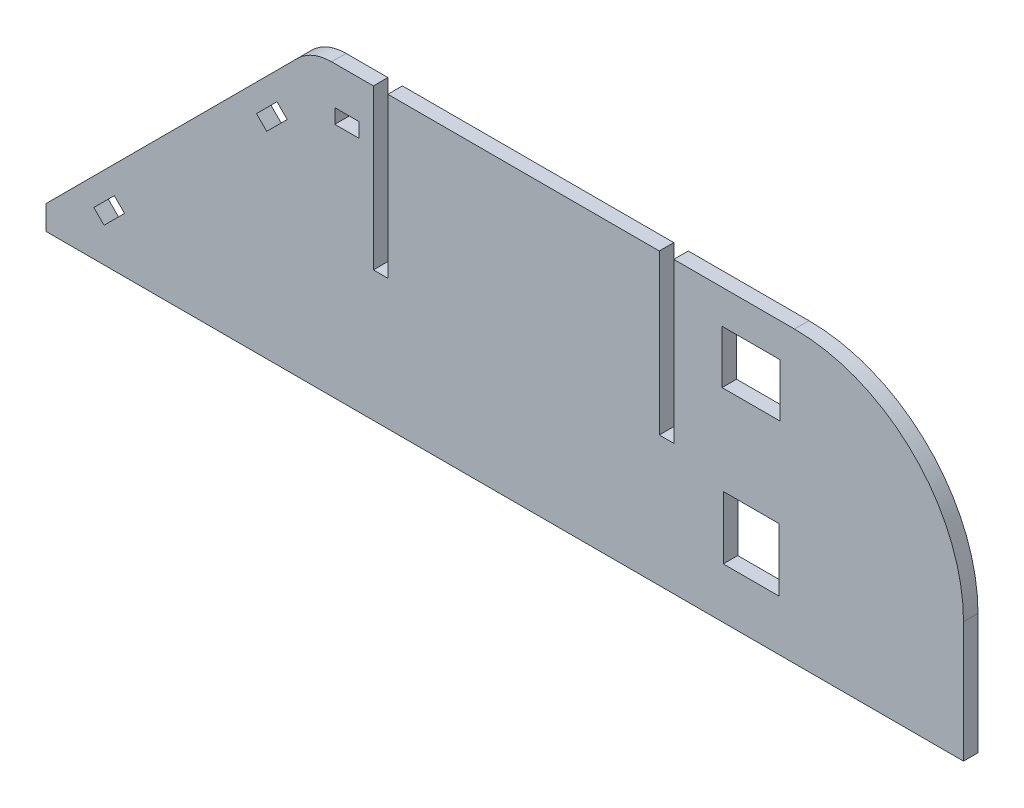
from build123d import *

# Parameters (mm, degrees)
SALIENTE_EXTRUIR1_DEPTH = 3
REDONDEO1_R             = 35
CROQUIS2_W              = 3
CROQUIS2_H              = 33
CORTAR_EXTRUIR1_DEPTH   = 4
CROQUIS3_W              = 11.5
CROQUIS3_H              = 13
CORTAR_EXTRUIR2_DEPTH   = 4
CROQUIS4_W              = 12
CROQUIS4_H              = 11
CORTAR_EXTRUIR3_DEPTH   = 4
REDONDEO2_R             = 10
CORTAR_EXTRUIR4_DEPTH   = 4
CROQUIS6_W              = 5
CROQUIS6_H              = 3
CORTAR_EXTRUIR5_DEPTH   = 4


with BuildPart() as part:
    # Croquis1 → Saliente-Extruir1 (new body)
    with BuildSketch(Plane.XY):
        Polygon((-21.5, 30), (-40, 30), (-95, -25), (-95, -30), (-21.5, -30), (-18.5, -30), (95, -30), (95, 30), (-18.5, 30), align=None)
    extrude(amount=SALIENTE_EXTRUIR1_DEPTH)

    # Redondeo1
    redondeo1_edges = [part.edges().sort_by_distance(p)[0] for p in [
        (95, 30, 1.5),
    ]]
    fillet(redondeo1_edges, radius=REDONDEO1_R)

    # Croquis2 → Cortar-Extruir1 (cut, through all)
    with BuildSketch(Plane.XY.offset(3)):
        with Locations((33.5, 13.5)):
            Rectangle(CROQUIS2_W, CROQUIS2_H)
        with Locations((-25.7, 13.5)):
            Rectangle(CROQUIS2_W, CROQUIS2_H)
    extrude(amount=-CORTAR_EXTRUIR1_DEPTH, mode=Mode.SUBTRACT)

    # Croquis3 → Cortar-Extruir2 (cut, through all)
    with BuildSketch(Plane(origin=(0, 0, 0), x_dir=(-1, 0, 0), z_dir=(0, 0, -1))):
        with Locations((-51, -13)):
            Rectangle(CROQUIS3_W, CROQUIS3_H)
    extrude(amount=-CORTAR_EXTRUIR2_DEPTH, mode=Mode.SUBTRACT)

    # Croquis4 → Cortar-Extruir3 (cut, through all)
    with BuildSketch(Plane(origin=(0, 0, 0), x_dir=(-1, 0, 0), z_dir=(0, 0, -1))):
        with Locations((-51, 17.5)):
            Rectangle(CROQUIS4_W, CROQUIS4_H)
    extrude(amount=-CORTAR_EXTRUIR3_DEPTH, mode=Mode.SUBTRACT)

    # Redondeo2
    redondeo2_edges = [part.edges().sort_by_distance(p)[0] for p in [
        (-40, 30, 1.5),
    ]]
    fillet(redondeo2_edges, radius=REDONDEO2_R)

    # Croquis5 → Cortar-Extruir4 (cut, through all)
    with BuildSketch(Plane(origin=(0, 0, 0), x_dir=(-1, 0, 0), z_dir=(0, 0, -1))):
        Polygon((47.171572875, 17.171572875), (45.050252532, 15.050252532), (49.292893219, 10.807611845), (51.414213562, 12.928932188), align=None)
        Polygon((85.100505063, -20.757359313), (82.97918472, -22.878679656), (78.736544033, -18.636038969), (80.857864376, -16.514718626), align=None)
    extrude(amount=-CORTAR_EXTRUIR4_DEPTH, mode=Mode.SUBTRACT)

    # Croquis6 → Cortar-Extruir5 (cut, through all)
    with BuildSketch(Plane(origin=(0, 0, 0), x_dir=(-1, 0, 0), z_dir=(0, 0, -1))):
        with Locations((32.7, 20.61)):
            Rectangle(CROQUIS6_W, CROQUIS6_H)
    extrude(amount=-CORTAR_EXTRUIR5_DEPTH, mode=Mode.SUBTRACT)


solid = part.part
